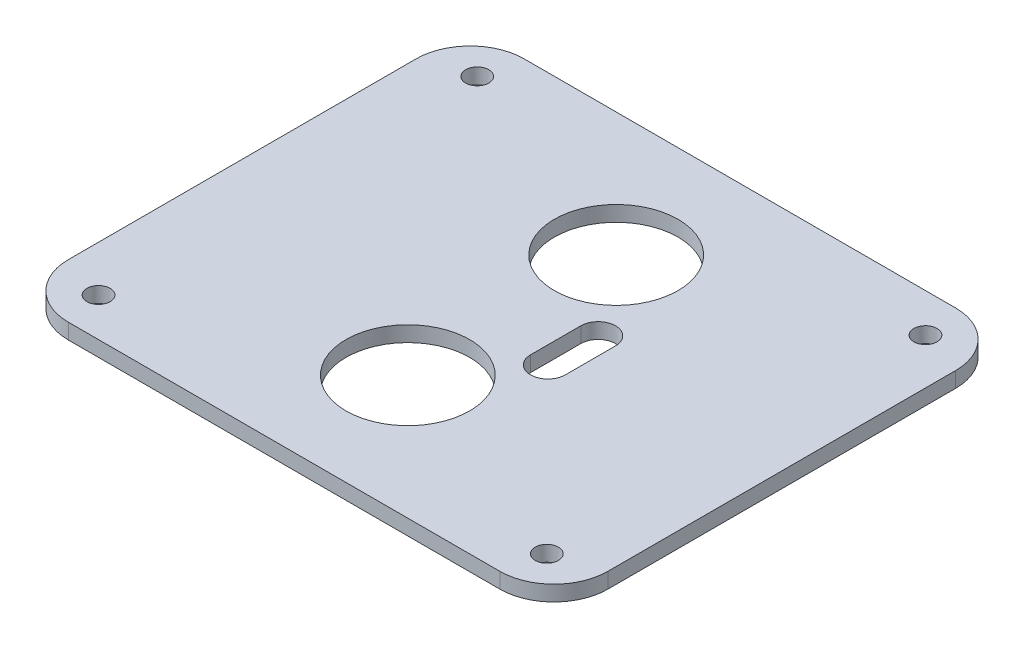
from build123d import *

# Parameters (mm, degrees)
SKETCH_2_W      = 69.836734694
SKETCH_2_H      = 59
SKETCH_2_R      = 8
SKETCH_2_R_2    = 1.5
EXTRUDE_1_DEPTH = 2
FILLET_1_R      = 7


with BuildPart() as part:
    # 草圖2 → 填料-伸長1 (new body)
    with BuildSketch(Plane(origin=(0, 0, 0), x_dir=(-1, 0, 0), z_dir=(0, 1, 0))):
        Rectangle(SKETCH_2_W, SKETCH_2_H)
        with Locations((0, 13.48)):
            Circle(SKETCH_2_R, mode=Mode.SUBTRACT)
        with Locations((0, -13.48)):
            Circle(SKETCH_2_R, mode=Mode.SUBTRACT)
        with Locations((29, 24.5)):
            Circle(SKETCH_2_R_2, mode=Mode.SUBTRACT)
        with Locations((29, -24.5)):
            Circle(SKETCH_2_R_2, mode=Mode.SUBTRACT)
        with Locations((-29, 24.5)):
            Circle(SKETCH_2_R_2, mode=Mode.SUBTRACT)
        with Locations((-29, -24.5)):
            Circle(SKETCH_2_R_2, mode=Mode.SUBTRACT)
        with BuildLine():
            Line((-5.65, 3.25), (-5.65, -3.25))
            ThreePointArc((-5.65, -3.25), (-7.9, -5.5), (-10.15, -3.25))
            Line((-10.15, -3.25), (-10.15, 3.25))
            ThreePointArc((-10.15, 3.25), (-7.9, 5.5), (-5.65, 3.25))
        make_face(mode=Mode.SUBTRACT)
    extrude(amount=EXTRUDE_1_DEPTH)

    # 圓角1
    fillet_1_edges = [part.edges().sort_by_distance(p)[0] for p in [
        (-34.918367347, 1, -29.5),
        (34.918367347, 1, -29.5),
        (34.918367347, 1, 29.5),
        (-34.918367347, 1, 29.5),
    ]]
    fillet(fillet_1_edges, radius=FILLET_1_R)


solid = part.part
